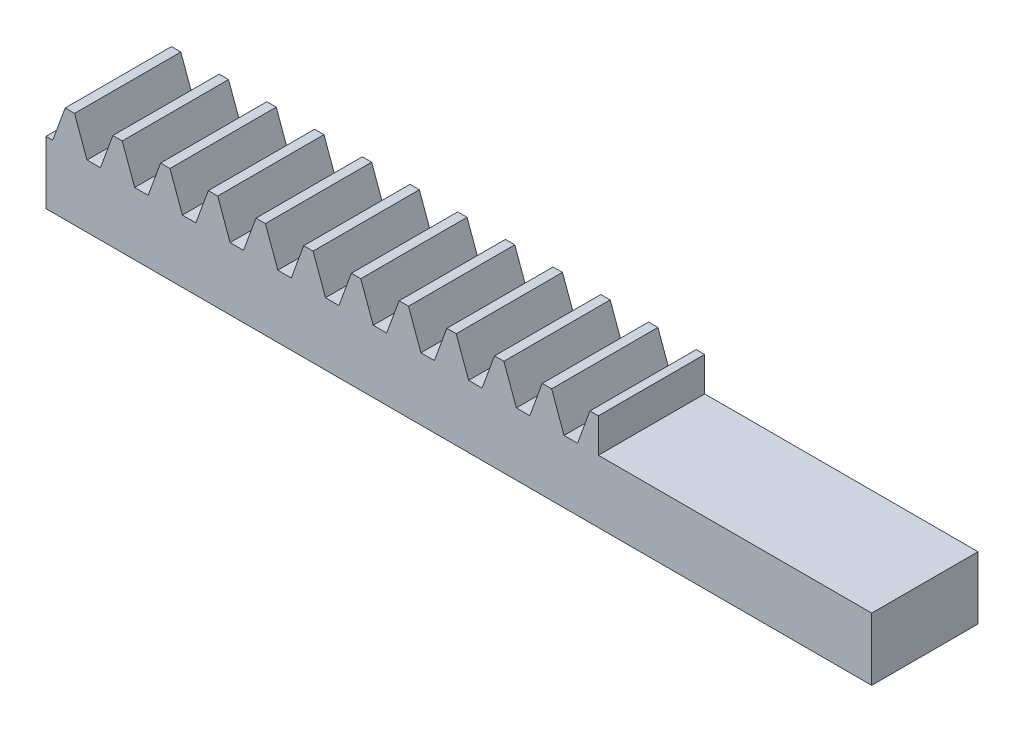
from build123d import *

# Parameters (mm, degrees)
BLANKSKE_W         = 21.75
BLANKSKE_H         = 2.55
BLANK_DEPTH        = 2.8
TOOTHCUTSIM_DEPTH  = 23.077250735
TEETHCUTS_COUNT    = 18
TEETHCUTS_PITCH    = 1.25663706
SKETCH1_W          = 7.2
SKETCH1_H          = 0.9
CUT_EXTRUDE1_DEPTH = 23.077250735


with BuildPart() as part:
    # BlankSke → Blank (new body)
    with BuildSketch(Plane.XY):
        with Locations((10.875, 1.275)):
            Rectangle(BLANKSKE_W, BLANKSKE_H)
    extrude(amount=-BLANK_DEPTH)

    # TooCutSkeSim → ToothCutSim (cut, through all)
    with BuildSketch(Plane.XY):
        Polygon((0.177174148, 1.65), (-0.177174148, 1.65), (-0.513992203, 2.5754), (0.513992203, 2.5754), align=None)
    toothcutsim = extrude(amount=-TOOTHCUTSIM_DEPTH, mode=Mode.SUBTRACT)

    # TeethCuts: ToothCutSim ×18
    with Locations(*[(i * TEETHCUTS_PITCH, 0, 0) for i in range(1, TEETHCUTS_COUNT)]):
        add(toothcutsim, mode=Mode.SUBTRACT)

    # Sketch1 → Cut-Extrude1 (cut, through all)
    with BuildSketch(Plane.XY):
        with Locations((18.15, 2.1)):
            Rectangle(SKETCH1_W, SKETCH1_H)
    extrude(amount=-CUT_EXTRUDE1_DEPTH, mode=Mode.SUBTRACT)


solid = part.part
